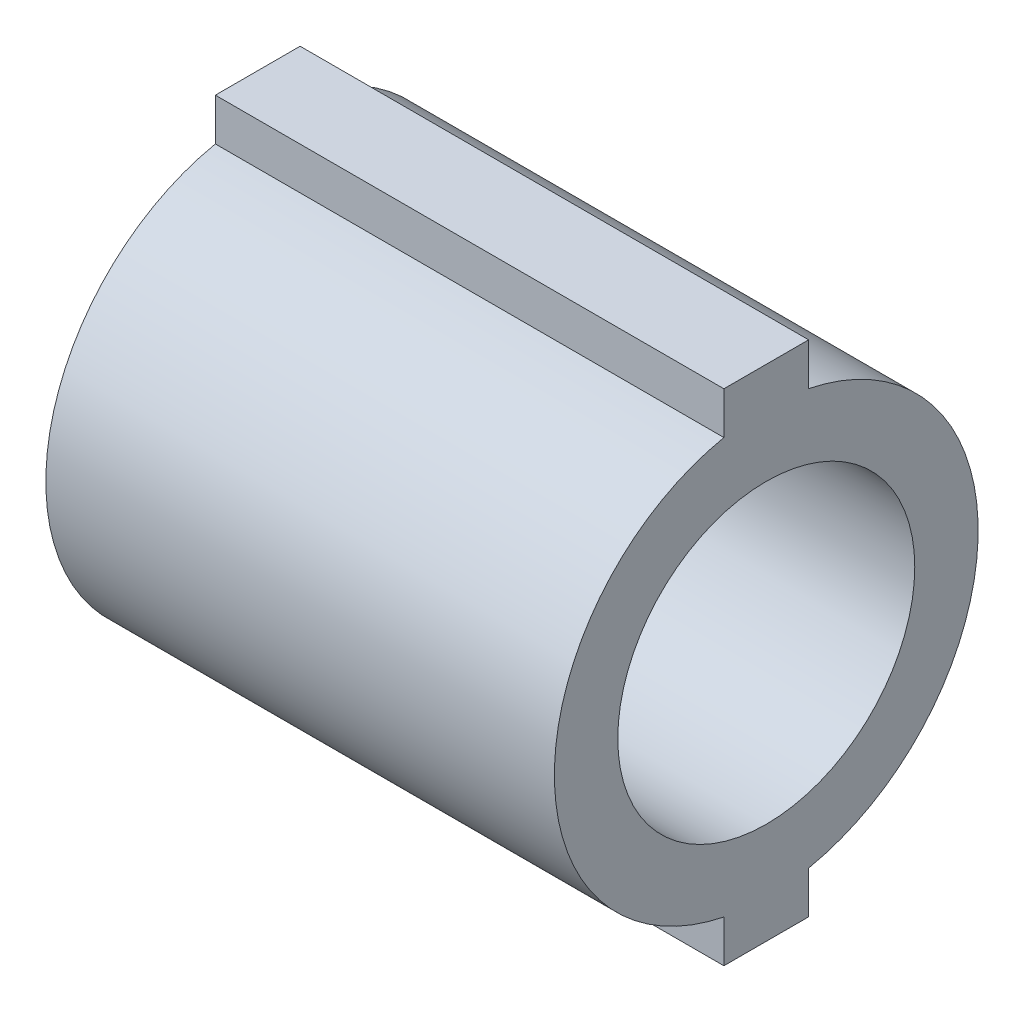
from build123d import *

# Parameters (mm, degrees)
SKETCH1_R           = 7.9375
BOSS_EXTRUDE1_DEPTH = 19.05
SKETCH2_W           = 3.175
SKETCH2_H           = 3.446915699
BOSS_EXTRUDE2_DEPTH = 19.05
SKETCH3_R           = 5.5626
CUT_EXTRUDE1_DEPTH  = 19.05


with BuildPart() as part:
    # Sketch1 → Boss-Extrude1 (new body)
    with BuildSketch(Plane(origin=(0, 0, 0), x_dir=(0, 0, -1), z_dir=(1, 0, 0))):
        Circle(SKETCH1_R)
    extrude(amount=BOSS_EXTRUDE1_DEPTH)

    # Sketch2 → Boss-Extrude2 (add)
    with BuildSketch(Plane.ZY):
        with Locations((0, 7.636442151)):
            Rectangle(SKETCH2_W, SKETCH2_H)
        with Locations((0, -7.636442151)):
            Rectangle(SKETCH2_W, SKETCH2_H)
    extrude(amount=-BOSS_EXTRUDE2_DEPTH)

    # Sketch3 → Cut-Extrude1 (cut)
    with BuildSketch(Plane.ZY):
        Circle(SKETCH3_R)
    extrude(amount=-CUT_EXTRUDE1_DEPTH, mode=Mode.SUBTRACT)


solid = part.part
